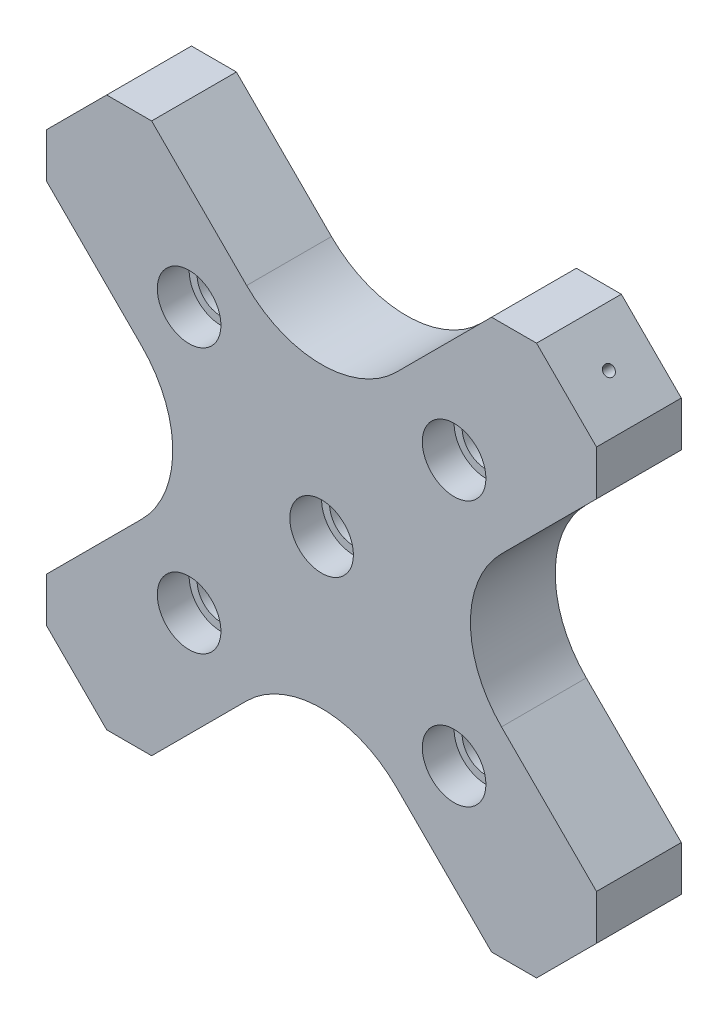
from build123d import *

# Parameters (mm, degrees)
ESQUISSE1_R               = 2.25
BOSS_EXTRU_1_DEPTH        = 8
CONG_1_R                  = 10
ESQUISSE2_R               = 0.5
ENL_V_MAT_EXTRU_1_DEPTH   = 10
ESQUISSE3_R               = 3
ENL_V_MAT_EXTRU_2_DEPTH   = 3
SYM_TRIE2_COPY_1_SKETCH_R = 0.5
SYM_TRIE2_COPY_1_DEPTH    = 10
SYM_TRIE2_COPY_2_SKETCH_R = 3
SYM_TRIE2_COPY_2_DEPTH    = 3


with BuildPart() as part:
    # Esquisse1 → Boss.-Extru.1 (new body)
    with BuildSketch(Plane.XY):
        Polygon((-9.899494937, 0), (-25.935028843, 16.035533906), (-25.935028843, 20.278174593), (-20.278174593, 25.935028843), (-16.035533906, 25.935028843), (0, 9.899494937), (16.035533906, 25.935028843), (20.278174593, 25.935028843), (25.935028843, 20.278174593), (25.935028843, 16.035533906), (9.899494937, 0), (25.935028843, -16.035533906), (25.935028843, -20.278174593), (20.278174593, -25.935028843), (16.035533906, -25.935028843), (0, -9.899494937), (-16.035533906, -25.935028843), (-20.278174593, -25.935028843), (-25.935028843, -20.278174593), (-25.935028843, -16.035533906), align=None)
        with Locations((-12.5, -12.5)):
            Circle(ESQUISSE1_R, mode=Mode.SUBTRACT)
        with Locations((12.5, -12.5)):
            Circle(ESQUISSE1_R, mode=Mode.SUBTRACT)
        Circle(ESQUISSE1_R, mode=Mode.SUBTRACT)
        with Locations((12.5, 12.5)):
            Circle(ESQUISSE1_R, mode=Mode.SUBTRACT)
        with Locations((-12.5, 12.5)):
            Circle(ESQUISSE1_R, mode=Mode.SUBTRACT)
    extrude(amount=BOSS_EXTRU_1_DEPTH)

    # Congé1
    cong_1_edges = [part.edges().sort_by_distance(p)[0] for p in [
        (0, 9.899494937, 4),
        (9.899494937, 0, 4),
        (0, -9.899494937, 4),
        (-9.899494937, 0, 4),
    ]]
    fillet(cong_1_edges, radius=CONG_1_R)

    # Esquisse2 → Enlèv. mat.-Extru.1 (cut)
    with BuildSketch(Plane(origin=(23.106601718, 23.106601718, 0), x_dir=(0, 0, -1), z_dir=(0.707106781, 0.707106781, 0))):
        with Locations((-4, 0)):
            Circle(ESQUISSE2_R)
    enl_v_mat_extru_1 = extrude(amount=-ENL_V_MAT_EXTRU_1_DEPTH, mode=Mode.SUBTRACT)

    # Esquisse3 → Enlèv. mat.-Extru.2 (cut)
    with BuildSketch(Plane.XY.offset(8)):
        with Locations((12.5, 12.5)):
            Circle(ESQUISSE3_R)
        Circle(ESQUISSE3_R)
    enl_v_mat_extru_2 = extrude(amount=-ENL_V_MAT_EXTRU_2_DEPTH, mode=Mode.SUBTRACT)

    # Symétrie1: Enlèv. mat.-Extru.1, Enlèv. mat.-Extru.2 across plane
    add(enl_v_mat_extru_1.mirror(Plane.ZX), mode=Mode.SUBTRACT)
    add(enl_v_mat_extru_2.mirror(Plane.ZX), mode=Mode.SUBTRACT)

    # Symétrie2: Enlèv. mat.-Extru.1, Enlèv. mat.-Extru.2 across plane
    add(enl_v_mat_extru_1.mirror(Plane(origin=(0, 0, 0), x_dir=(0, 0, 1), z_dir=(1, 0, 0))), mode=Mode.SUBTRACT)
    add(enl_v_mat_extru_2.mirror(Plane(origin=(0, 0, 0), x_dir=(0, 0, 1), z_dir=(1, 0, 0))), mode=Mode.SUBTRACT)

    # Symétrie2 copy 1 sketch → Symétrie2 copy 1 (cut)
    with BuildSketch(Plane(origin=(-23.106601718, -23.106601718, 0), x_dir=(0, 0, -1), z_dir=(-0.707106781, -0.707106781, 0))):
        with Locations((-4, 0)):
            Circle(SYM_TRIE2_COPY_1_SKETCH_R)
    extrude(amount=-SYM_TRIE2_COPY_1_DEPTH, mode=Mode.SUBTRACT)

    # Symétrie2 copy 2 sketch → Symétrie2 copy 2 (cut)
    with BuildSketch(Plane(origin=(0, 0, 8), x_dir=(-1, 0, 0), z_dir=(0, 0, 1))):
        with Locations((12.5, 12.5)):
            Circle(SYM_TRIE2_COPY_2_SKETCH_R)
        Circle(SYM_TRIE2_COPY_2_SKETCH_R)
    extrude(amount=-SYM_TRIE2_COPY_2_DEPTH, mode=Mode.SUBTRACT)


solid = part.part
